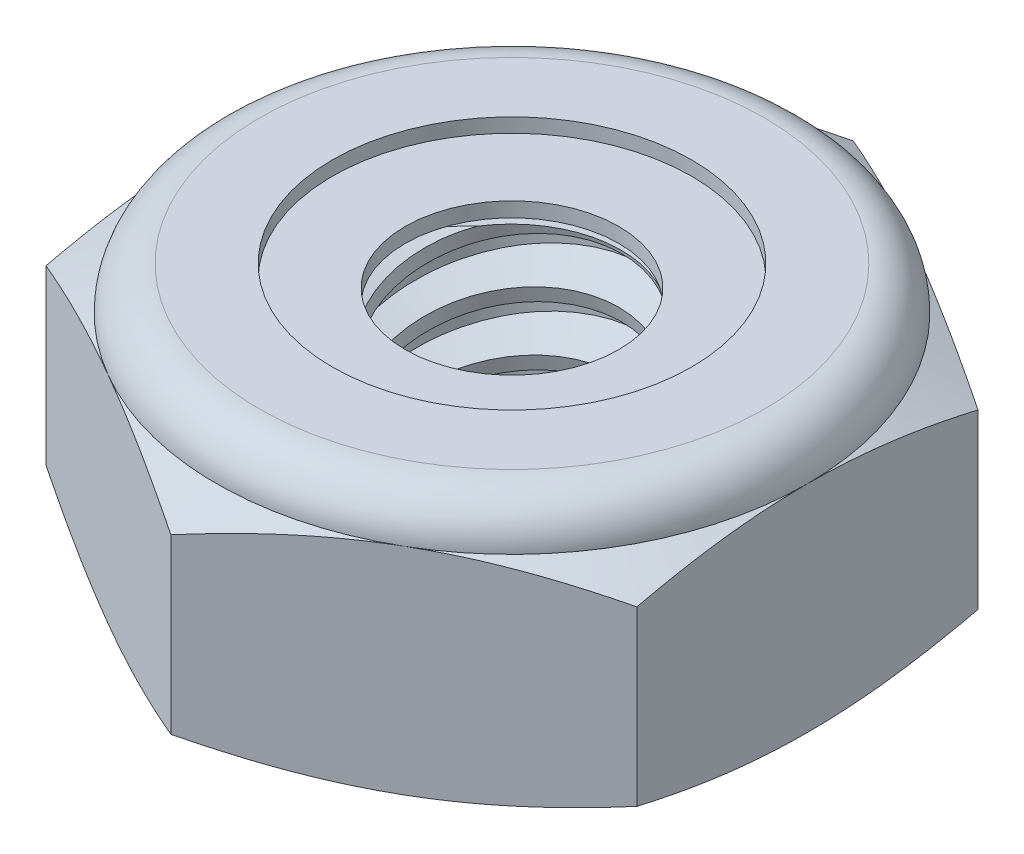
from build123d import *

# Parameters (mm, degrees)
EXTRUDE1_DEPTH      = 2.778125
SKETCH2_W           = 1.4224
SKETCH2_H           = 2.778125
LPATTERN1_COUNT     = 4
LPATTERN1_PITCH     = 0.635
LPATTERN1_COL_COUNT = 2
LPATTERN1_COL_PITCH = 0.635


with BuildPart() as part:
    # Sketch1 → Extrude1 (new body)
    with BuildSketch(Plane(origin=(0, 0, 0), x_dir=(1, 0, 0), z_dir=(0, 1, 0))):
        Polygon((0, 3.666174209), (-3.175, 1.833087105), (-3.175, -1.833087105), (0, -3.666174209), (3.175, -1.833087105), (3.175, 1.833087105), align=None)
    extrude(amount=EXTRUDE1_DEPTH)

    # Sketch4 → Cut-Revolve2 (revolve, cut)
    with BuildSketch(Plane(origin=(0, 0, 0), x_dir=(0, 0, -1), z_dir=(1, 0, 0))):
        Polygon((0, 2.778125), (1.4224, 2.778125), (1.147473684, 2.649924754), (1.147473684, 0.128200246), (1.4224, 0), (0, 0), align=None)
    revolve(axis=Axis((0, 2.778125, 0), (0, 1, 0)), mode=Mode.SUBTRACT)


with BuildPart() as body_2:
    # Sketch2 → Revolve1 (revolve)
    with BuildSketch(Plane(origin=(0, 0, 0), x_dir=(0, 0, -1), z_dir=(1, 0, 0))):
        with Locations((0.7112, 1.3890625)):
            Rectangle(SKETCH2_W, SKETCH2_H)
    revolve(axis=Axis((0, -1.4224, 0), (0, 1, 0)))

    # Sketch3 → Cut-Revolve1 (revolve, cut)
    with BuildSketch(Plane(origin=(0, 0, 0), x_dir=(0, 0, -1), z_dir=(1, 0, 0))):
        Polygon((1.439692084, 2.700656462), (1.560736676, 2.158376693), (1.182057853, 2.277171117), (1.147473684, 2.432108194), align=None)
    cut_revolve1 = revolve(axis=Axis((0, 2.778125, 0.152561988), (0, -0.975981586, -0.217853033)), mode=Mode.SUBTRACT)

    # LPattern1: Cut-Revolve1 ×4
    with Locations(*[(0, -i * LPATTERN1_PITCH, 0) for i in range(1, LPATTERN1_COUNT)]):
        add(cut_revolve1, mode=Mode.SUBTRACT)

    # LPattern1 col: Cut-Revolve1 ×2
    with Locations(*[(0, i * LPATTERN1_COL_PITCH, 0) for i in range(1, LPATTERN1_COL_COUNT)]):
        add(cut_revolve1, mode=Mode.SUBTRACT)


with BuildPart() as part_1:
    add(part.part)

    # Combine1: cut body 2
    add(body_2.part, mode=Mode.SUBTRACT)

    # Sketch5 → Cut-Revolve3 (revolve, cut)
    with BuildSketch(Plane(origin=(0, 0, 0), x_dir=(0, 0, -1), z_dir=(1, 0, 0))):
        with BuildLine():
            Line((0, 0), (3.175, 0))
            Line((3.175, 0), (3.666174209, 0.229038295))
            Line((3.666174209, 0.229038295), (3.666174209, 2.086065871))
            Line((3.666174209, 2.086065871), (3.175, 2.315104167))
            ThreePointArc((3.175, 2.315104167), (3.039384338, 2.642509338), (2.711979167, 2.778125))
            Line((2.711979167, 2.778125), (2.711979167, 4.048125))
            Line((2.711979167, 4.048125), (4.936174209, 4.048125))
            Line((4.936174209, 4.048125), (4.936174209, -1.27))
            Line((4.936174209, -1.27), (0, -1.27))
            Line((0, -1.27), (0, 0))
        make_face()
    revolve(axis=Axis((0, 0, 0), (0, 1, 0)), mode=Mode.SUBTRACT)

    # Sketch6 → Cut-Revolve4 (revolve, cut)
    with BuildSketch(Plane(origin=(0, 0, 0), x_dir=(0, 0, -1), z_dir=(1, 0, 0))):
        with BuildLine():
            Line((0, 2.315104167), (3.0226, 2.315104167))
            ThreePointArc((3.0226, 2.315104167), (2.931621264, 2.534746264), (2.711979167, 2.625725))
            Line((2.711979167, 2.625725), (1.929726426, 2.625725))
            Line((1.929726426, 2.625725), (1.929726426, 4.048125))
            Line((1.929726426, 4.048125), (0, 4.048125))
            Line((0, 4.048125), (0, 2.315104167))
        make_face()
    revolve(axis=Axis((0, 4.048125, 0), (0, 1, 0)), mode=Mode.SUBTRACT)


with BuildPart() as body_2_2:
    # Sketch7 → Revolve2 (revolve)
    with BuildSketch(Plane(origin=(0, 0, 0), x_dir=(0, 0, -1), z_dir=(1, 0, 0))):
        with BuildLine():
            Line((1.147473684, 2.391304167), (2.933669688, 2.391304167))
            ThreePointArc((2.933669688, 2.391304167), (2.848159671, 2.505912964), (2.711979167, 2.549525))
            Line((2.711979167, 2.549525), (1.147473684, 2.549525))
            Line((1.147473684, 2.549525), (1.147473684, 2.391304167))
        make_face()
    revolve(axis=Axis((0, 2.391304167, 0), (0, 1, 0)))


solid = Compound([part_1.part, body_2_2.part])
